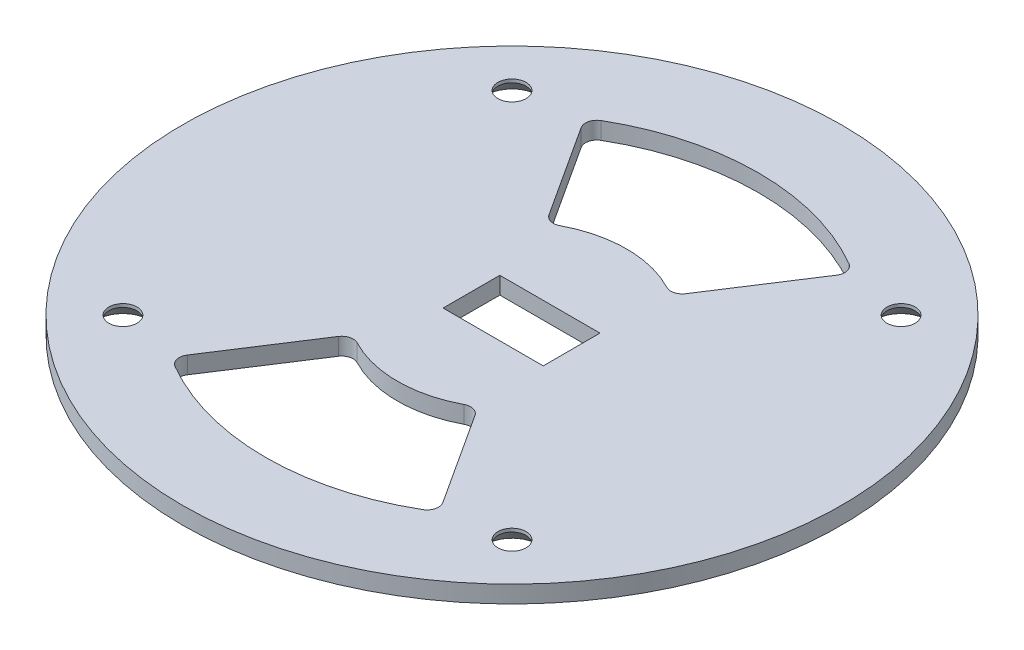
from build123d import *

# Parameters (mm, degrees)
SKETCH1_R                                     = 57.5
SKETCH1_R_2                                   = 0.5
SKETCH1_W                                     = 9.325
SKETCH1_H                                     = 9.9
BOSS_EXTRUDE1_DEPTH                           = 3
CSK_FOR_8_FLAT_HEAD_SOCKET_CAP_SCREW1_A_COUNT = 2
CSK_FOR_8_FLAT_HEAD_SOCKET_CAP_SCREW1_A_PITCH = 67.882250994
CSK_FOR_8_FLAT_HEAD_SOCKET_CAP_SCRE_2_COUNT   = 2
CSK_FOR_8_FLAT_HEAD_SOCKET_CAP_SCRE_2_PITCH   = 96
CSK_FOR_8_FLAT_HEAD_SOCKET_CAP_SCRE_3_COUNT   = 2
CSK_FOR_8_FLAT_HEAD_SOCKET_CAP_SCRE_3_PITCH   = 67.882250994
SKETCH5_W                                     = 4.075
SKETCH5_H                                     = 9.9
CUT_EXTRUDE2_DEPTH                            = 4
CUT_EXTRUDE4_DEPTH                            = 4
FILLET3_R                                     = 2


with BuildPart() as part:
    # Sketch1 → Boss-Extrude1 (new body)
    with BuildSketch(Plane(origin=(0, 0, 0), x_dir=(1, 0, 0), z_dir=(0, 1, 0))):
        Circle(SKETCH1_R)
        with Locations((-33.941125497, 33.941125497)):
            Circle(SKETCH1_R_2, mode=Mode.SUBTRACT)
        with Locations((33.941125497, 33.941125497)):
            Circle(SKETCH1_R_2, mode=Mode.SUBTRACT)
        with Locations((33.941125497, -33.941125497)):
            Circle(SKETCH1_R_2, mode=Mode.SUBTRACT)
        with Locations((-33.941125497, -33.941125497)):
            Circle(SKETCH1_R_2, mode=Mode.SUBTRACT)
        with Locations((1.6625, 0)):
            Rectangle(SKETCH1_W, SKETCH1_H, mode=Mode.SUBTRACT)
    extrude(amount=BOSS_EXTRUDE1_DEPTH)

    # Sketch2 → CSK for #8 Flat Head Socket Cap Screw1 (revolve, cut)
    with BuildSketch(Plane(origin=(-33.941125497, 0, 33.941125497), x_dir=(0, 0, -1), z_dir=(1, 0, 0))):
        Polygon((0, 0), (0, 3), (2.45745, 3), (2.45745, 2.417901837), (4.5593, 0), align=None)
    csk_for_8_flat_head_socket_cap_screw1 = revolve(axis=Axis((-33.941125497, -6.35, 33.941125497), (0, 1, 0)), mode=Mode.SUBTRACT)

    # CSK for #8 Flat Head Socket Cap Screw1 a: CSK for #8 Flat Head Socket Cap Screw1 ×2
    with Locations(*[(i * CSK_FOR_8_FLAT_HEAD_SOCKET_CAP_SCREW1_A_PITCH, 0, 0) for i in range(1, CSK_FOR_8_FLAT_HEAD_SOCKET_CAP_SCREW1_A_COUNT)]):
        add(csk_for_8_flat_head_socket_cap_screw1, mode=Mode.SUBTRACT)

    # CSK for _8 Flat Head Socket Cap Scre 2: CSK for #8 Flat Head Socket Cap Screw1 ×2
    with Locations(*[Vector(0.707106781, 0, -0.707106781) * (i * CSK_FOR_8_FLAT_HEAD_SOCKET_CAP_SCRE_2_PITCH) for i in range(1, CSK_FOR_8_FLAT_HEAD_SOCKET_CAP_SCRE_2_COUNT)]):
        add(csk_for_8_flat_head_socket_cap_screw1, mode=Mode.SUBTRACT)

    # CSK for _8 Flat Head Socket Cap Scre 3: CSK for #8 Flat Head Socket Cap Screw1 ×2
    with Locations(*[(0, 0, -i * CSK_FOR_8_FLAT_HEAD_SOCKET_CAP_SCRE_3_PITCH) for i in range(1, CSK_FOR_8_FLAT_HEAD_SOCKET_CAP_SCRE_3_COUNT)]):
        add(csk_for_8_flat_head_socket_cap_screw1, mode=Mode.SUBTRACT)

    # Sketch5 → Cut-Extrude2 (cut, through all)
    with BuildSketch(Plane.XZ):
        with Locations((8.3625, 0)):
            Rectangle(SKETCH5_W, SKETCH5_H)
        with Locations((-5.0375, 0)):
            Rectangle(SKETCH5_W, SKETCH5_H)
    extrude(amount=-CUT_EXTRUDE2_DEPTH, mode=Mode.SUBTRACT)

    # Sketch10 → Cut-Extrude4 (cut, through all)
    with BuildSketch(Plane.XZ):
        with BuildLine():
            Line((23.40393029, 36.072926787), (10.885548972, 16.778105482))
            ThreePointArc((10.885548972, 16.778105482), (0, 20), (-10.885548972, 16.778105482))
            Line((-10.885548972, 16.778105482), (-23.40393029, 36.072926787))
            ThreePointArc((-23.40393029, 36.072926787), (0, 43), (23.40393029, 36.072926787))
        make_face()
        with BuildLine():
            Line((-23.40393029, -36.072926787), (-10.885548972, -16.778105482))
            ThreePointArc((-10.885548972, -16.778105482), (0, -20), (10.885548972, -16.778105482))
            Line((10.885548972, -16.778105482), (23.40393029, -36.072926787))
            ThreePointArc((23.40393029, -36.072926787), (0, -43), (-23.40393029, -36.072926787))
        make_face()
    extrude(amount=-CUT_EXTRUDE4_DEPTH, mode=Mode.SUBTRACT)

    # Fillet3
    fillet3_edges = [part.edges().sort_by_distance(p)[0] for p in [
        (10.885548972, 1.5, 16.778105482),
        (-10.885548972, 1.5, 16.778105482),
        (-10.885548972, 1.5, -16.778105482),
        (10.885548972, 1.5, -16.778105482),
        (23.40393029, 1.5, -36.072926787),
        (-23.40393029, 1.5, -36.072926787),
        (-23.40393029, 1.5, 36.072926787),
        (23.40393029, 1.5, 36.072926787),
    ]]
    fillet(fillet3_edges, radius=FILLET3_R)


solid = part.part
